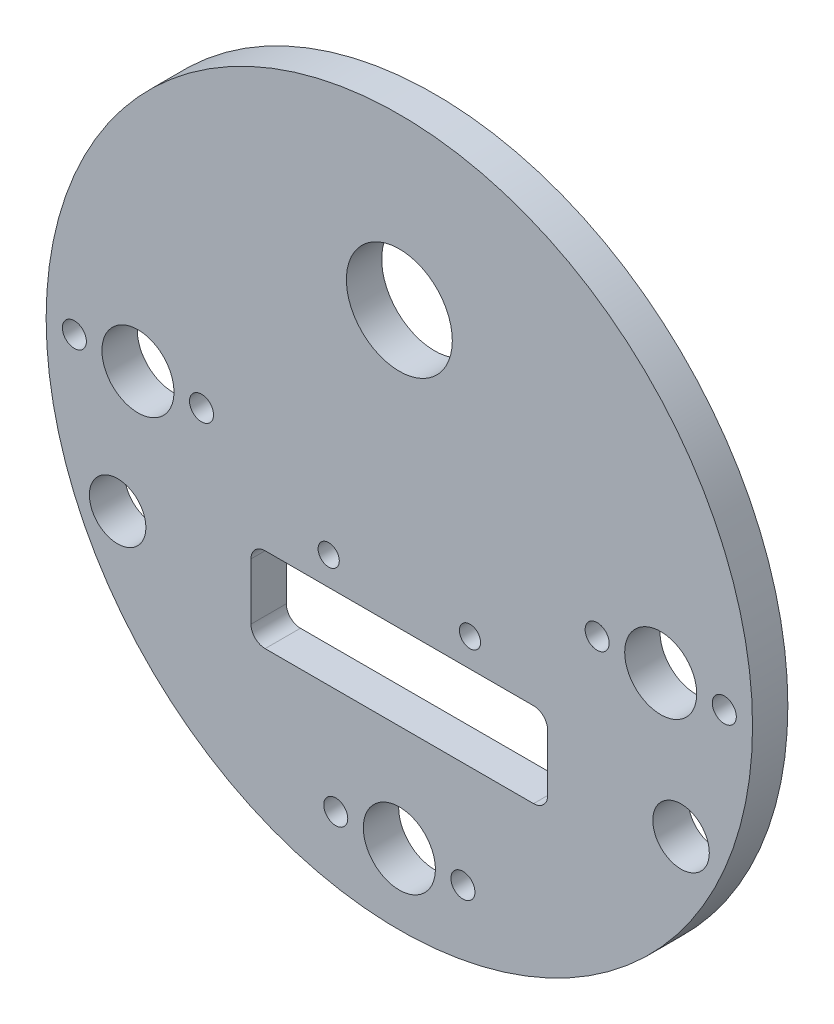
from build123d import *

# Parameters (mm, degrees)
SKETCH1_R                    = 50
BOSS_EXTRUDE1_DEPTH          = 5
F_10_2_10_2_DIAMETER_HOLE1_D = 10.2
M3_CLEARANCE_HOLE1_D         = 3.4
SKETCH9_R                    = 7.5
CUT_EXTRUDE1_DEPTH           = 10
SKETCH10_R                   = 1.5
CUT_EXTRUDE2_DEPTH           = 10
SKETCH11_R                   = 4
CUT_EXTRUDE3_DEPTH           = 10


with BuildPart() as part:
    # Sketch1 → Boss-Extrude1 (new body)
    with BuildSketch(Plane.XY):
        Circle(SKETCH1_R)
    extrude(amount=BOSS_EXTRUDE1_DEPTH)

    # Ø10.2 (10.2) Diameter Hole1 (through all)
    with Locations(Plane(origin=(0, 0, 0), x_dir=(-1, 0, 0), z_dir=(0, 0, -1))):
        with Locations((37, 0), (-37, 0), (0, -40)):
            Hole(F_10_2_10_2_DIAMETER_HOLE1_D / 2)

    # M3 Clearance Hole1 (through all)
    with Locations(Plane.XY.offset(5)):
        with Locations((46, 0), (28, 0), (9, -40), (-9, -40), (-46, 0), (-28, 0)):
            Hole(M3_CLEARANCE_HOLE1_D / 2)

    # Sketch9 → Cut-Extrude1 (cut)
    with BuildSketch(Plane.XY.offset(5)):
        with Locations((0, 26)):
            Circle(SKETCH9_R)
    extrude(amount=-CUT_EXTRUDE1_DEPTH, mode=Mode.SUBTRACT)

    # Sketch10 → Cut-Extrude2 (cut)
    with BuildSketch(Plane.XY.offset(5)):
        with Locations((10, -9)):
            Circle(SKETCH10_R)
        with Locations((-10, -9)):
            Circle(SKETCH10_R)
        with BuildLine():
            Line((-19, -13), (19, -13))
            ThreePointArc((19, -13), (20.414213562, -13.585786438), (21, -15))
            Line((21, -15), (21, -23))
            ThreePointArc((21, -23), (20.414213562, -24.414213562), (19, -25))
            Line((19, -25), (-19, -25))
            ThreePointArc((-19, -25), (-20.414213562, -24.414213562), (-21, -23))
            Line((-21, -23), (-21, -15))
            ThreePointArc((-21, -15), (-20.414213562, -13.585786438), (-19, -13))
        make_face()
    extrude(amount=-CUT_EXTRUDE2_DEPTH, mode=Mode.SUBTRACT)

    # Sketch11 → Cut-Extrude3 (cut)
    with BuildSketch(Plane.XY.offset(5)):
        with Locations((-39.87754263, -18.595203517)):
            Circle(SKETCH11_R)
        with Locations((39.87754263, -18.595203517)):
            Circle(SKETCH11_R)
    extrude(amount=-CUT_EXTRUDE3_DEPTH, mode=Mode.SUBTRACT)


solid = part.part
